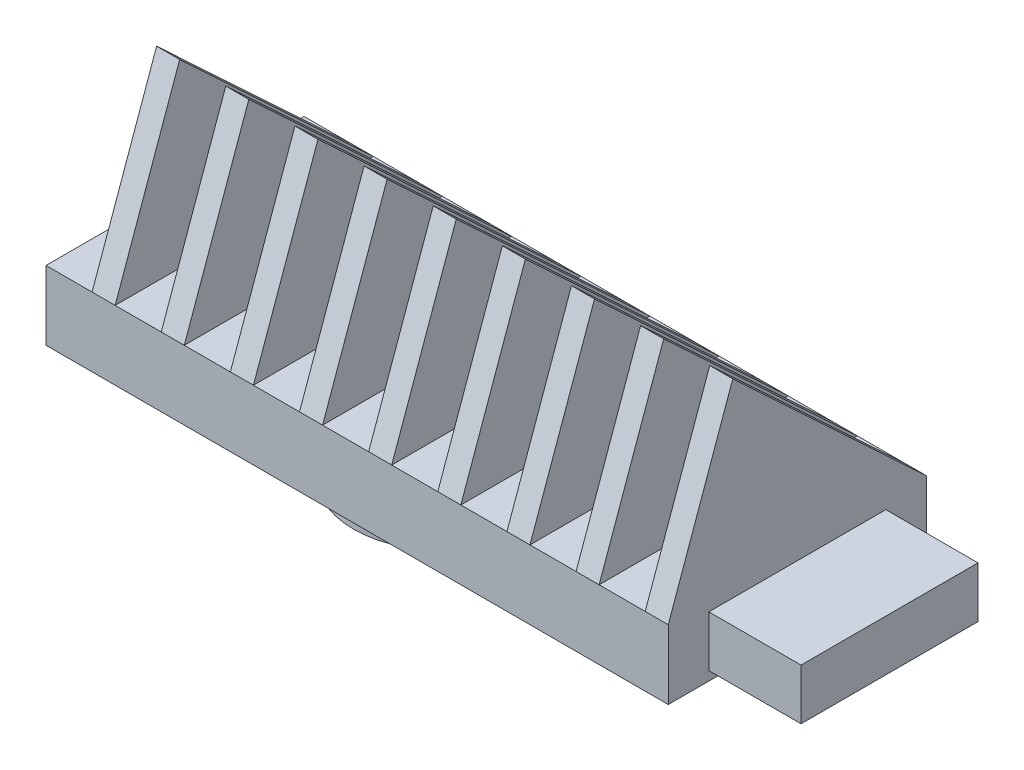
from build123d import *

# Parameters (mm, degrees)
SKETCH1_W           = 211.1375
SKETCH1_H           = 35.56
BOSS_EXTRUDE1_DEPTH = 9.525
SKETCH6_R           = 12.192
BOSS_EXTRUDE4_DEPTH = 6.35
BOSS_EXTRUDE5_DEPTH = 3.175
LPATTERN1_COUNT     = 22
LPATTERN1_PITCH     = 9.525
SKETCH10_W          = 59.980257814
SKETCH10_H          = 67.271975432
CUT_EXTRUDE1_DEPTH  = 125.4125
SKETCH11_W          = 24.384
SKETCH11_H          = 7.0104
BOSS_EXTRUDE6_DEPTH = 12.7


with BuildPart() as part:
    # Sketch1 → Boss-Extrude1 (new body)
    with BuildSketch(Plane(origin=(0, 0, 0), x_dir=(1, 0, 0), z_dir=(0, 1, 0))):
        with Locations((-105.56875, 17.78)):
            Rectangle(SKETCH1_W, SKETCH1_H)
    extrude(amount=BOSS_EXTRUDE1_DEPTH)

    # Sketch6 → Boss-Extrude4 (add)
    with BuildSketch(Plane(origin=(0, 0, 0), x_dir=(-1, 0, 0), z_dir=(0, -1, 0))):
        with Locations((105.56875, 17.78)):
            Circle(SKETCH6_R)
        with Locations((36.79825, 17.78)):
            Circle(SKETCH6_R)
        with Locations((174.33925, 17.78)):
            Circle(SKETCH6_R)
    extrude(amount=BOSS_EXTRUDE4_DEPTH)

    # Sketch9 → Boss-Extrude5 (add)
    with BuildSketch(Plane.ZY.offset(204.7875)):
        Polygon((-35.56, 9.525), (0, 9.525), (-8.89, 34.417), align=None)
    boss_extrude5 = extrude(amount=-BOSS_EXTRUDE5_DEPTH)

    # LPattern1: Boss-Extrude5 ×22
    with Locations(*[(i * LPATTERN1_PITCH, 0, 0) for i in range(1, LPATTERN1_COUNT)]):
        add(boss_extrude5)

    # Sketch10 → Cut-Extrude1 (cut)
    with BuildSketch(Plane(origin=(0, 0, 0), x_dir=(0, 0, -1), z_dir=(1, 0, 0))):
        with Locations((17.78, 4.683648782)):
            Rectangle(SKETCH10_W, SKETCH10_H)
    extrude(amount=-CUT_EXTRUDE1_DEPTH, mode=Mode.SUBTRACT)

    # Sketch11 → Boss-Extrude6 (add)
    with BuildSketch(Plane(origin=(-125.4125, 0, 0), x_dir=(0, 0, -1), z_dir=(1, 0, 0))):
        with Locations((17.78, 4.7625)):
            Rectangle(SKETCH11_W, SKETCH11_H)
    extrude(amount=BOSS_EXTRUDE6_DEPTH)


solid = part.part
